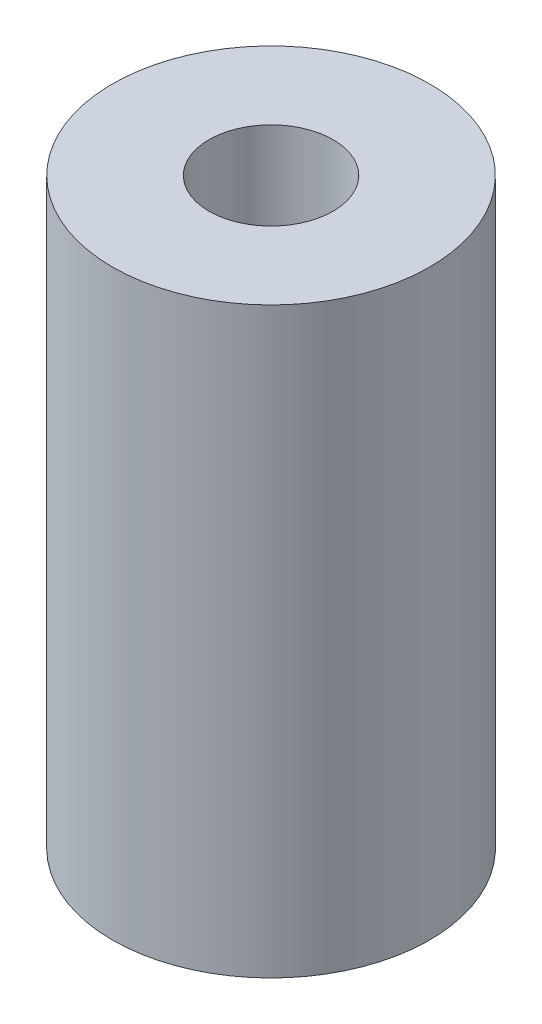
from build123d import *

# Parameters (mm, degrees)
SKETCH2_R           = 9.525
SKETCH2_R_2         = 3.7258
BOSS_EXTRUDE1_DEPTH = 35


with BuildPart() as part:
    # Sketch2 → Boss-Extrude1 (new body)
    with BuildSketch(Plane(origin=(0, 0, 0), x_dir=(1, 0, 0), z_dir=(0, 1, 0))):
        Circle(SKETCH2_R)
        Circle(SKETCH2_R_2, mode=Mode.SUBTRACT)
    extrude(amount=BOSS_EXTRUDE1_DEPTH)


solid = part.part
